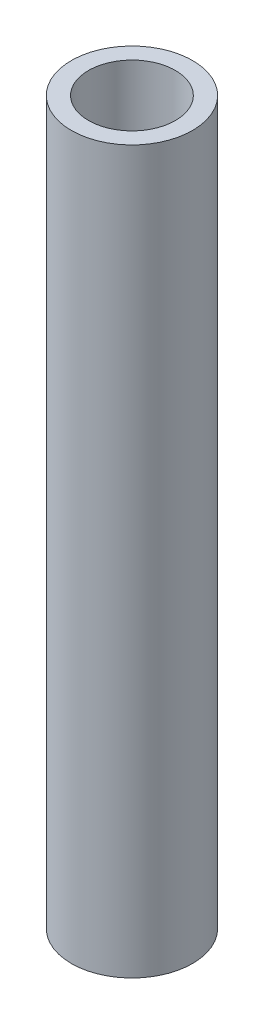
from build123d import *

# Parameters (mm, degrees)
SKETCH1_R           = 10.668
SKETCH1_R_2         = 7.6454
BOSS_EXTRUDE1_DEPTH = 127


with BuildPart() as part:
    # Sketch1 → Boss-Extrude1 (new body)
    with BuildSketch(Plane(origin=(0, 0, 0), x_dir=(1, 0, 0), z_dir=(0, 1, 0))):
        Circle(SKETCH1_R)
        Circle(SKETCH1_R_2, mode=Mode.SUBTRACT)
    extrude(amount=BOSS_EXTRUDE1_DEPTH)


solid = part.part
